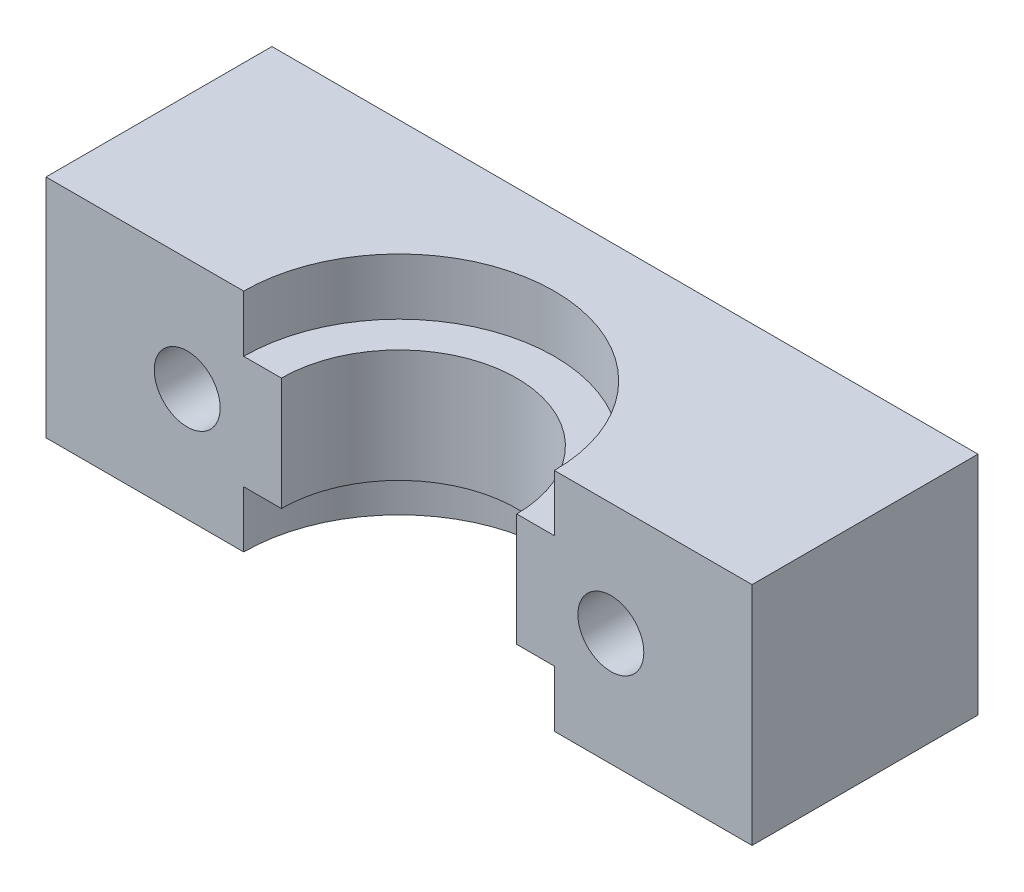
from build123d import *

# Parameters (mm, degrees)
BOSS_EXTRUDE1_DEPTH     = 6
CUT_EXTRUDE1_START      = 3
SKETCH2_R               = 8.25
CUT_EXTRUDE1_DEPTH      = 3
CUT_EXTRUDE2_REACH      = 14
SKETCH3_R               = 1.75
SKETCH4_R               = 3
CUT_EXTRUDE3_DEPTH      = 1
CUT_EXTRUDE3_DEPTH_BACK = 3


with BuildPart() as part:
    # Sketch1 → Boss-Extrude1 (new body, symmetric)
    with BuildSketch(Plane(origin=(0, 0, 0), x_dir=(1, 0, 0), z_dir=(0, 1, 0))):
        with BuildLine():
            Line((-6.25, 0), (-18.75, 0))
            Line((-18.75, 0), (-18.75, 12))
            Line((-18.75, 12), (18.75, 12))
            Line((18.75, 12), (18.75, 0))
            Line((18.75, 0), (6.25, 0))
            ThreePointArc((6.25, 0), (0, 6.25), (-6.25, 0))
        make_face()
    extrude(amount=BOSS_EXTRUDE1_DEPTH, both=True)

    # Sketch2 → Cut-Extrude1 (cut)
    with BuildSketch(Plane(origin=(0, 0, 0), x_dir=(1, 0, 0), z_dir=(0, 1, 0)).offset(CUT_EXTRUDE1_START)):
        Circle(SKETCH2_R)
    cut_extrude1 = extrude(amount=CUT_EXTRUDE1_DEPTH, mode=Mode.SUBTRACT)

    # Mirror1: Cut-Extrude1 across plane
    add(cut_extrude1.mirror(Plane.ZX), mode=Mode.SUBTRACT)

    # Sketch3 → Cut-Extrude2 (cut, up to next)
    with BuildSketch(Plane.XY, mode=Mode.PRIVATE) as cut_extrude2_sk1:
        with Locations((-11.25, 0)):
            Circle(SKETCH3_R)
    cut_extrude2_tool1 = extrude(cut_extrude2_sk1.sketch, amount=-CUT_EXTRUDE2_REACH, mode=Mode.PRIVATE) & part.part
    add(cut_extrude2_tool1.solids().sort_by_distance((-11.25, 0, 0))[0], mode=Mode.SUBTRACT)
    # Sketch3 → Cut-Extrude2 (cut, up to next)
    with BuildSketch(Plane.XY, mode=Mode.PRIVATE) as cut_extrude2_sk2:
        with Locations((11.25, 0)):
            Circle(SKETCH3_R)
    cut_extrude2_tool2 = extrude(cut_extrude2_sk2.sketch, amount=-CUT_EXTRUDE2_REACH, mode=Mode.PRIVATE) & part.part
    add(cut_extrude2_tool2.solids().sort_by_distance((11.25, 0, 0))[0], mode=Mode.SUBTRACT)

    # Sketch4 → Cut-Extrude3 (cut, two sides)
    with BuildSketch(Plane(origin=(0, 0, -12), x_dir=(-1, 0, 0), z_dir=(0, 0, -1))) as cut_extrude3_sk:
        with Locations((11.25, 0)):
            Circle(SKETCH4_R)
        with Locations((-11.25, 0)):
            Circle(SKETCH4_R)
    extrude(amount=CUT_EXTRUDE3_DEPTH, mode=Mode.SUBTRACT)
    extrude(cut_extrude3_sk.sketch, amount=-CUT_EXTRUDE3_DEPTH_BACK, mode=Mode.SUBTRACT)


solid = part.part
